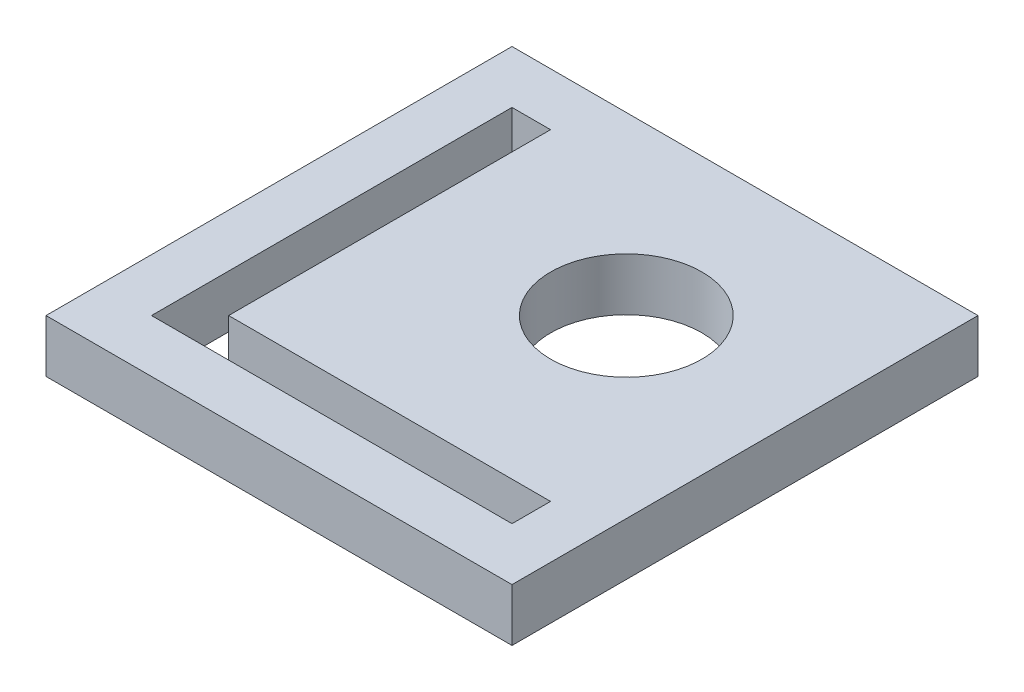
from build123d import *

# Parameters (mm, degrees)
SKETCH1_W           = 26.5
SKETCH1_H           = 26.5
BOSS_EXTRUDE1_DEPTH = 3
SKETCH2_R           = 4.3
CUT_EXTRUDE1_DEPTH  = 4


with BuildPart() as part:
    # Sketch1 → Boss-Extrude1 (new body)
    with BuildSketch(Plane(origin=(0, 0, 0), x_dir=(1, 0, 0), z_dir=(0, 1, 0))):
        with Locations((13.25, 13.25)):
            Rectangle(SKETCH1_W, SKETCH1_H)
        Polygon((3, 23.5), (3, 3), (23.5, 3), (23.5, 5.1933835), (5.1933835, 5.1933835), (5.1933835, 23.5), align=None, mode=Mode.SUBTRACT)
    extrude(amount=BOSS_EXTRUDE1_DEPTH)

    # Sketch2 → Cut-Extrude1 (cut, through all)
    with BuildSketch(Plane(origin=(0, 3, 0), x_dir=(1, 0, 0), z_dir=(0, 1, 0))):
        with Locations((16.5, 16.5)):
            Circle(SKETCH2_R)
    extrude(amount=-CUT_EXTRUDE1_DEPTH, mode=Mode.SUBTRACT)


solid = part.part
